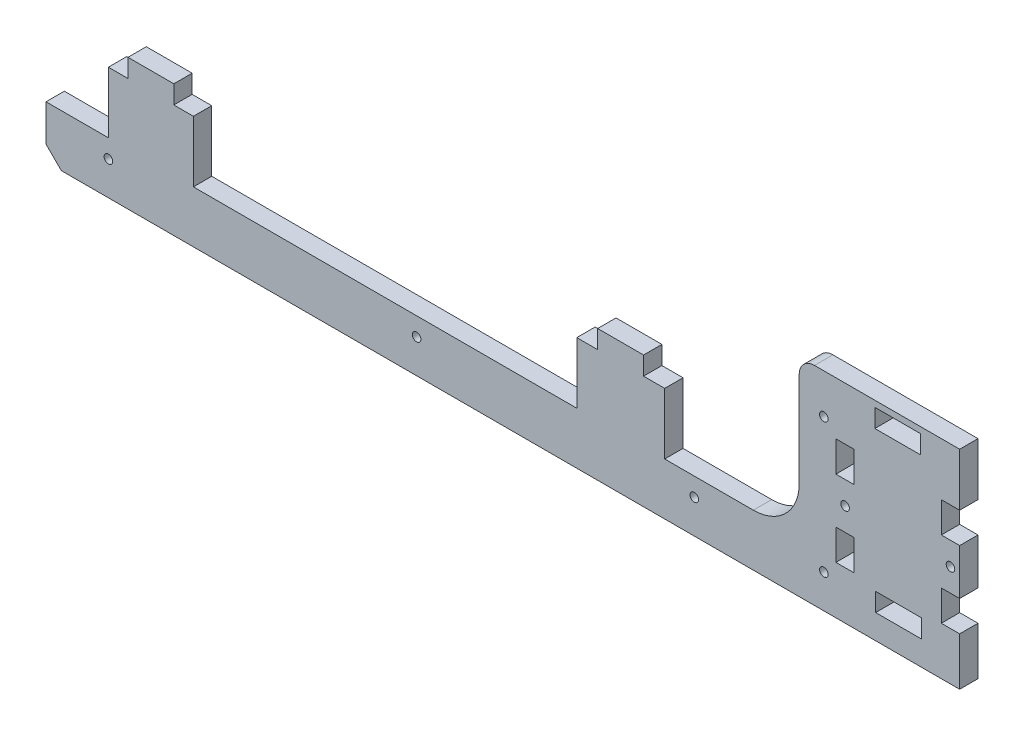
from build123d import *

# Parameters (mm, degrees)
SKETCH_1_R      = 1.4
SKETCH_1_W      = 15
SKETCH_1_H      = 6
SKETCH_1_W_2    = 6
SKETCH_1_H_2    = 10
EXTRUDE_1_DEPTH = 6


with BuildPart() as part:
    # Эскиз1 → Бобышка-Вытянуть1 (new body)
    with BuildSketch(Plane.XY):
        with BuildLine():
            Line((96.920798757, 2), (96.920798757, 25))
            Line((96.920798757, 25), (96.920798757, 33))
            ThreePointArc((96.920798757, 33), (98.385264851, 36.535533906), (101.920798757, 38))
            Line((101.920798757, 38), (149.389201243, 38))
            Line((149.389201243, 38), (149.389201243, 30))
            Line((149.389201243, 30), (149.389201243, 20.709265489))
            Line((149.389201243, 20.709265489), (143.389201243, 20.709265489))
            Line((143.389201243, 20.709265489), (143.389201243, 10.709265489))
            Line((143.389201243, 10.709265489), (149.389201243, 10.709265489))
            Line((149.389201243, 10.709265489), (149.389201243, -4.290734511))
            Line((149.389201243, -4.290734511), (143.389201243, -4.290734511))
            Line((143.389201243, -4.290734511), (143.389201243, -14.290734511))
            Line((143.389201243, -14.290734511), (149.389201243, -14.290734511))
            Line((149.389201243, -14.290734511), (149.389201243, -30))
            Line((149.389201243, -30), (-144.389201243, -30))
            Line((-144.389201243, -30), (-149.389201243, -25))
            Line((-149.389201243, -25), (-149.389201243, -13))
            Line((-149.389201243, -13), (-128.98858016, -13))
            Line((-128.98858016, -13), (-128.98858016, 7))
            Line((-128.98858016, 7), (-122.58858016, 7))
            Line((-122.58858016, 7), (-122.58858016, 13))
            Line((-122.58858016, 13), (-107.58858016, 13))
            Line((-107.58858016, 13), (-107.58858016, 7))
            Line((-107.58858016, 7), (-101.18858016, 7))
            Line((-101.18858016, 7), (-101.18858016, -13))
            Line((-101.18858016, -13), (24.179035237, -13))
            Line((24.179035237, -13), (24.179035237, 7))
            Line((24.179035237, 7), (31.021419837, 7))
            Line((31.021419837, 7), (31.021419837, 13))
            Line((31.021419837, 13), (46.021419837, 13))
            Line((46.021419837, 13), (46.021419837, 7))
            Line((46.021419837, 7), (52.929060017, 7))
            Line((52.929060017, 7), (52.929060017, -13))
            Line((52.929060017, -13), (81.920798757, -13))
            ThreePointArc((81.920798757, -13), (92.527400475, -8.606601718), (96.920798757, 2))
        make_face()
        with Locations((104.970798757, -19)):
            Circle(SKETCH_1_R, mode=Mode.SUBTRACT)
        with Locations((104.970798757, 25)):
            Circle(SKETCH_1_R, mode=Mode.SUBTRACT)
        with Locations((111.920798757, 3.209265489)):
            Circle(SKETCH_1_R, mode=Mode.SUBTRACT)
        with Locations((146.389201243, 3.209265489)):
            Circle(SKETCH_1_R, mode=Mode.SUBTRACT)
        with Locations((-128.98858016, -19)):
            Circle(SKETCH_1_R, mode=Mode.SUBTRACT)
        with Locations((-28.18858016, -19)):
            Circle(SKETCH_1_R, mode=Mode.SUBTRACT)
        with Locations((62.61141984, -19)):
            Circle(SKETCH_1_R, mode=Mode.SUBTRACT)
        with Locations((129.420798757, -19)):
            Rectangle(SKETCH_1_W, SKETCH_1_H, mode=Mode.SUBTRACT)
        with Locations((111.920798757, 15.709265489)):
            Rectangle(SKETCH_1_W_2, SKETCH_1_H_2, mode=Mode.SUBTRACT)
        with Locations((111.920798757, -9.290734511)):
            Rectangle(SKETCH_1_W_2, SKETCH_1_H_2, mode=Mode.SUBTRACT)
        with Locations((129.155798757, 33)):
            Rectangle(SKETCH_1_W, SKETCH_1_H, mode=Mode.SUBTRACT)
    extrude(amount=EXTRUDE_1_DEPTH)


solid = part.part
